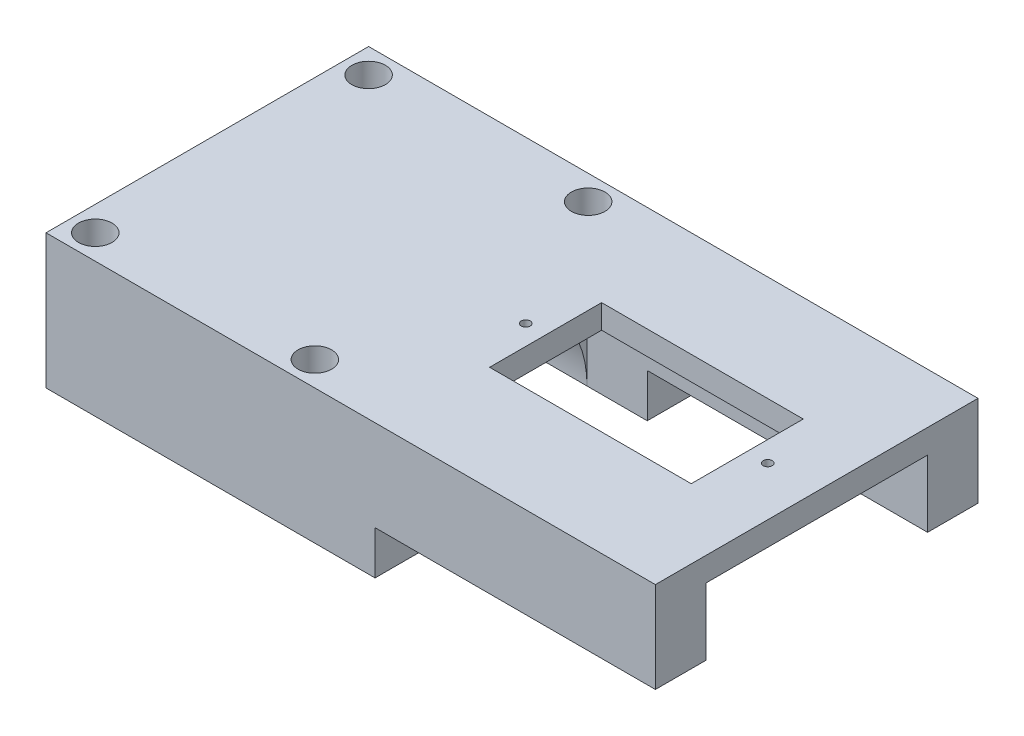
from build123d import *

# Parameters (mm, degrees)
SKETCH1_W               = 30
SKETCH1_H               = 36
BOSS_EXTRUDE1_DEPTH     = 30
SKETCH3_R               = 12.375
CUT_EXTRUDE1_DEPTH      = 40
SKETCH5_R               = 1.875
CUT_EXTRUDE2_DEPTH      = 40
CUT_EXTRUDE3_START      = 15
SKETCH7_W               = 36
SKETCH7_H               = 15
CUT_EXTRUDE3_DEPTH      = 31
BOSS_EXTRUDE2_DEPTH     = 38
SKETCH9_R               = 0.5
SKETCH9_W               = 22.5
SKETCH9_H               = 12.5
CUT_EXTRUDE4_DEPTH      = 10
SKETCH10_W              = 31.281266854
SKETCH10_H              = 4.861672308
CUT_EXTRUDE6_DEPTH      = 31.375
CUT_EXTRUDE6_DEPTH_BACK = 6.625


with BuildPart() as part:
    # Sketch1 → Boss-Extrude1 (new body)
    with BuildSketch(Plane(origin=(0, 0, 0), x_dir=(1, 0, 0), z_dir=(0, 1, 0))):
        Rectangle(SKETCH1_W, SKETCH1_H)
    extrude(amount=BOSS_EXTRUDE1_DEPTH)

    # Sketch3 → Cut-Extrude1 (cut)
    with BuildSketch(Plane(origin=(15, 0, 0), x_dir=(0, 0, -1), z_dir=(1, 0, 0))):
        with Locations((0, 15)):
            Circle(SKETCH3_R)
    extrude(amount=-CUT_EXTRUDE1_DEPTH, mode=Mode.SUBTRACT)

    # Sketch5 → Cut-Extrude2 (cut)
    with BuildSketch(Plane(origin=(0, 30, 0), x_dir=(1, 0, 0), z_dir=(0, 1, 0))):
        with Locations((-12.25, 15.25)):
            Circle(SKETCH5_R)
        with Locations((-12.25, -15.25)):
            Circle(SKETCH5_R)
        with Locations((12.25, -15.25)):
            Circle(SKETCH5_R)
        with Locations((12.25, 15.25)):
            Circle(SKETCH5_R)
    extrude(amount=-CUT_EXTRUDE2_DEPTH, mode=Mode.SUBTRACT)

    # Sketch7 → Cut-Extrude3 (cut, through all)
    with BuildSketch(Plane(origin=(0, 0, 0), x_dir=(0, 0, -1), z_dir=(1, 0, 0)).offset(CUT_EXTRUDE3_START)):
        with Locations((0, 7.5)):
            Rectangle(SKETCH7_W, SKETCH7_H)
    extrude(amount=-CUT_EXTRUDE3_DEPTH, mode=Mode.SUBTRACT)

    # Sketch8 → Boss-Extrude2 (add)
    with BuildSketch(Plane(origin=(15, 0, 0), x_dir=(0, 0, -1), z_dir=(1, 0, 0))):
        Polygon((-18, 30), (18, 30), (18, 27.331397605), (18, 15), (12.375, 15), (12.375, 27.331397605), (-12.375, 27.331397605), (-12.375, 15), (-18, 15), (-18, 27.331397605), align=None)
    extrude(amount=BOSS_EXTRUDE2_DEPTH)

    # Sketch9 → Cut-Extrude4 (cut)
    with BuildSketch(Plane(origin=(0, 30, 0), x_dir=(1, 0, 0), z_dir=(0, 1, 0))):
        with Locations((20.532846914, 0)):
            Circle(SKETCH9_R)
        with Locations((47.532846914, 0)):
            Circle(SKETCH9_R)
        with Locations((34, 0)):
            Rectangle(SKETCH9_W, SKETCH9_H)
    extrude(amount=-CUT_EXTRUDE4_DEPTH, mode=Mode.SUBTRACT)

    # Sketch10 → Cut-Extrude6 (cut, two sides)
    with BuildSketch(Plane(origin=(0, 0, 12.375), x_dir=(-1, 0, 0), z_dir=(0, 0, -1))) as cut_extrude6_sk:
        with Locations((-37.359366573, 17.430836154)):
            Rectangle(SKETCH10_W, SKETCH10_H)
    extrude(amount=CUT_EXTRUDE6_DEPTH, mode=Mode.SUBTRACT)
    extrude(cut_extrude6_sk.sketch, amount=-CUT_EXTRUDE6_DEPTH_BACK, mode=Mode.SUBTRACT)


solid = part.part
